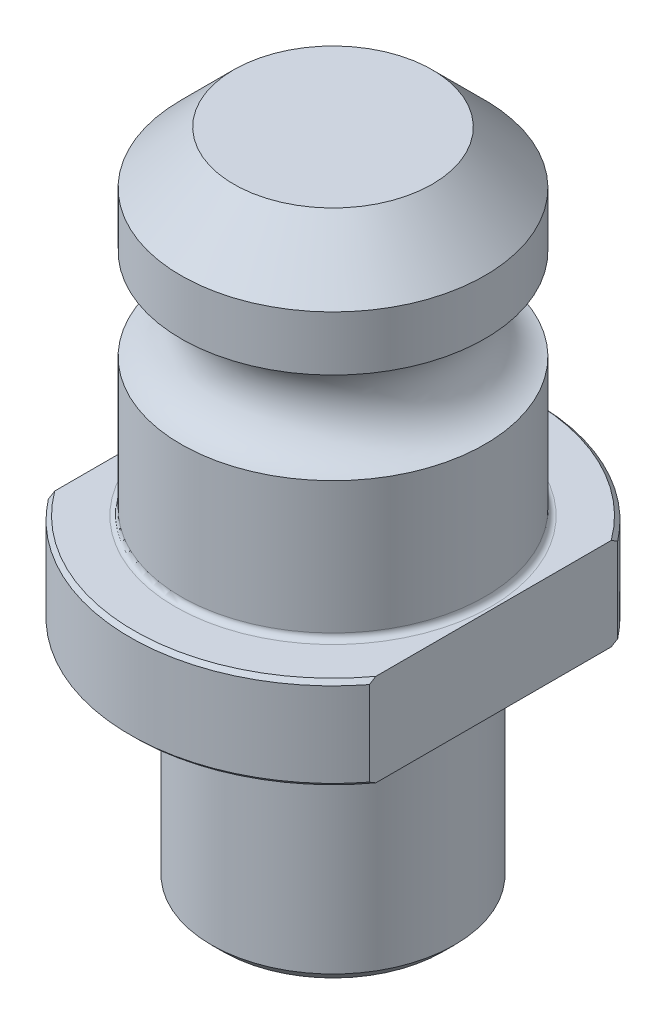
from build123d import *

# Parameters (mm, degrees)
CHAMFER1_SIZE      = 0.508
CHAMFER2_SIZE      = 1.524
CUT_EXTRUDE1_DEPTH = 43.1132
FILLET1_R          = 0.762


with BuildPart() as part:
    # Sketch1 → Revolve1 (revolve)
    with BuildSketch(Plane.XY):
        with BuildLine():
            Line((0, 55.9816), (0, -30.0736))
            Line((0, -30.0736), (-15.875, -30.0736))
            Line((-15.875, -30.0736), (-15.875, -4.318))
            Line((-15.875, -4.318), (-13.6017, -4.318))
            Line((-13.6017, -4.318), (-13.6017, -1.27))
            ThreePointArc((-13.6017, -1.27), (-13.973674388, -0.371974388), (-14.8717, 0))
            Line((-14.8717, 0), (-26.4922, 0))
            Line((-26.4922, 0), (-26.4922, 12.0396))
            Line((-26.4922, 12.0396), (-19.8374, 12.0396))
            Line((-19.8374, 12.0396), (-19.8374, 30.0228))
            ThreePointArc((-19.8374, 30.0228), (-14.859, 35.9918), (-19.8374, 41.9608))
            Line((-19.8374, 41.9608), (-19.8374, 49.0982))
            Line((-19.8374, 49.0982), (-12.954, 55.9816))
            Line((-12.954, 55.9816), (0, 55.9816))
        make_face()
    revolve(axis=Axis((0, -30.0736, 0), (0, -1, 0)))

    # Chamfer1
    chamfer1_edges = [part.edges().sort_by_distance(p)[0] for p in [
        (26.4922, 12.0396, 0),
        (26.4922, 0, 0),
    ]]
    chamfer(chamfer1_edges, length=CHAMFER1_SIZE)

    # Chamfer2
    chamfer2_edges = [part.edges().sort_by_distance(p)[0] for p in [
        (15.875, -30.0736, 0),
    ]]
    chamfer(chamfer2_edges, length=CHAMFER2_SIZE)

    # Sketch2 → Cut-Extrude1 (cut, through all)
    with BuildSketch(Plane(origin=(0, 12.0396, 0), x_dir=(1, 0, 0), z_dir=(0, 1, 0))):
        with BuildLine():
            Line((-20.955, 16.208782676), (-20.955, -16.208782676))
            ThreePointArc((-20.955, -16.208782676), (-26.4922, 0), (-20.955, 16.208782676))
        make_face()
        with BuildLine():
            Line((20.955, 16.208782676), (20.955, -16.208782676))
            ThreePointArc((20.955, -16.208782676), (26.4922, 0), (20.955, 16.208782676))
        make_face()
    extrude(amount=-CUT_EXTRUDE1_DEPTH, mode=Mode.SUBTRACT)

    # Fillet1
    fillet1_edges = [part.edges().sort_by_distance(p)[0] for p in [
        (19.8374, 12.0396, 0),
    ]]
    fillet(fillet1_edges, radius=FILLET1_R)


solid = part.part
